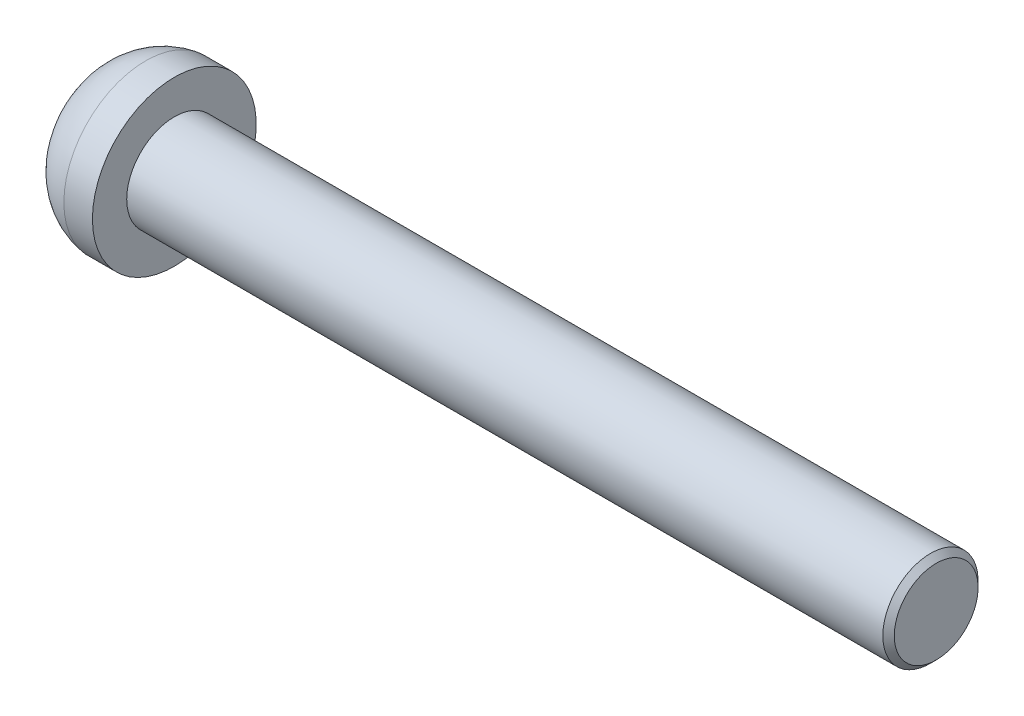
from build123d import *

# Parameters (mm, degrees)
CHAMFER1_SIZE      = 0.3
CUT_EXTRUDE1_DEPTH = 2


with BuildPart() as part:
    # Sketch1 → Revolve1 (revolve)
    with BuildSketch(Plane.XY):
        with BuildLine():
            Line((0, 0), (44, 0))
            Line((44, 0), (44, 2.5))
            Line((44, 2.5), (4, 2.5))
            Line((4, 2.5), (4, 4.3))
            Line((4, 4.3), (2.5, 4.3))
            ThreePointArc((2.5, 4.3), (1.027835828, 3.70856135), (0, 2.5))
            Line((0, 2.5), (0, 0))
        make_face()
    revolve(axis=Axis((0, 0, 0), (1, 0, 0)))

    # Chamfer1
    chamfer1_edges = [part.edges().sort_by_distance(p)[0] for p in [
        (44, -2.5, 0),
    ]]
    chamfer(chamfer1_edges, length=CHAMFER1_SIZE)

    # Sketch2 → Cut-Extrude1 (cut)
    with BuildSketch(Plane.ZY):
        Polygon((0, 2.309401077), (-2, 1.154700538), (-2, -1.154700538), (0, -2.309401077), (2, -1.154700538), (2, 1.154700538), align=None)
    extrude(amount=-CUT_EXTRUDE1_DEPTH, mode=Mode.SUBTRACT)


solid = part.part
